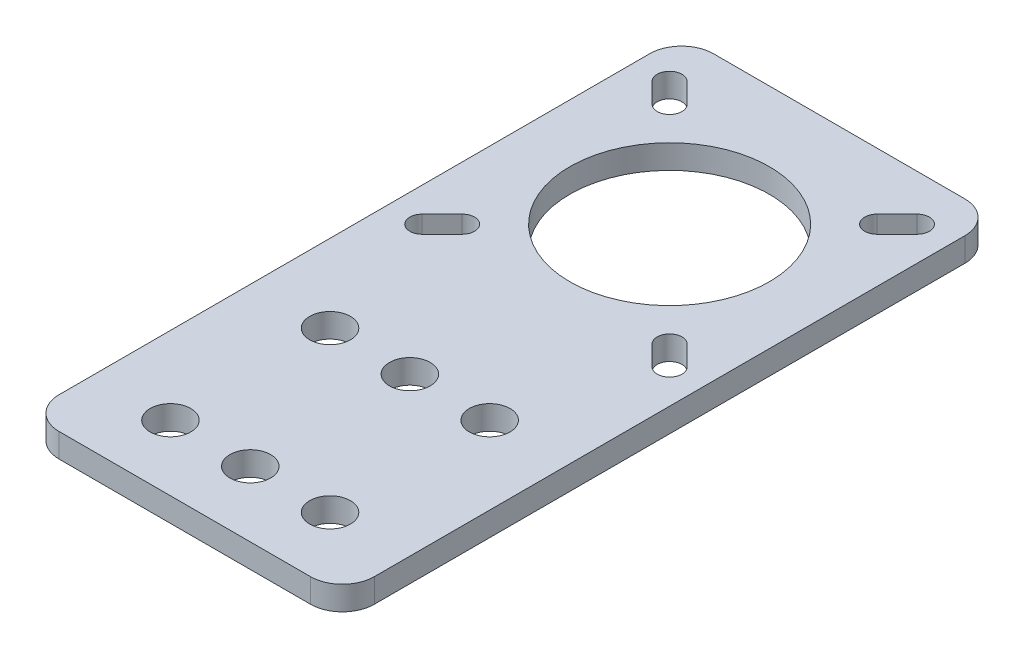
from build123d import *

# Parameters (mm, degrees)
SKETCH1_R           = 12.5
SKETCH1_R_2         = 2.55
BOSS_EXTRUDE1_DEPTH = 3


with BuildPart() as part:
    # Sketch1 → Boss-Extrude1 (new body)
    with BuildSketch(Plane(origin=(0, 0, 0), x_dir=(1, 0, 0), z_dir=(0, 1, 0))):
        with BuildLine():
            Line((15.75, -60.75), (-15.75, -60.75))
            ThreePointArc((-15.75, -60.75), (-18.578427125, -59.578427125), (-19.75, -56.75))
            Line((-19.75, -56.75), (-19.75, 17.25))
            ThreePointArc((-19.75, 17.25), (-18.578427125, 20.078427125), (-15.75, 21.25))
            Line((-15.75, 21.25), (15.75, 21.25))
            ThreePointArc((15.75, 21.25), (18.578427125, 20.078427125), (19.75, 17.25))
            Line((19.75, 17.25), (19.75, -56.75))
            ThreePointArc((19.75, -56.75), (18.578427125, -59.578427125), (15.75, -60.75))
        make_face()
        Circle(SKETCH1_R, mode=Mode.SUBTRACT)
        with Locations((10, -52.55)):
            Circle(SKETCH1_R_2, mode=Mode.SUBTRACT)
        with Locations((10, -32.55)):
            Circle(SKETCH1_R_2, mode=Mode.SUBTRACT)
        with Locations((0, -52.55)):
            Circle(SKETCH1_R_2, mode=Mode.SUBTRACT)
        with Locations((0, -32.55)):
            Circle(SKETCH1_R_2, mode=Mode.SUBTRACT)
        with Locations((-10, -52.55)):
            Circle(SKETCH1_R_2, mode=Mode.SUBTRACT)
        with Locations((-10, -32.55)):
            Circle(SKETCH1_R_2, mode=Mode.SUBTRACT)
        with BuildLine():
            Line((11.903984489, 14.096015511), (14.403984489, 16.596015511))
            ThreePointArc((14.403984489, 16.596015511), (16.596015511, 16.596015511), (16.596015511, 14.403984489))
            Line((16.596015511, 14.403984489), (14.096015511, 11.903984489))
            ThreePointArc((14.096015511, 11.903984489), (11.903984489, 11.903984489), (11.903984489, 14.096015511))
        make_face(mode=Mode.SUBTRACT)
        with BuildLine():
            Line((-11.903984489, 14.096015511), (-14.403984489, 16.596015511))
            ThreePointArc((-14.403984489, 16.596015511), (-16.596015511, 16.596015511), (-16.596015511, 14.403984489))
            Line((-16.596015511, 14.403984489), (-14.096015511, 11.903984489))
            ThreePointArc((-14.096015511, 11.903984489), (-11.903984489, 11.903984489), (-11.903984489, 14.096015511))
        make_face(mode=Mode.SUBTRACT)
        with BuildLine():
            Line((-11.903984489, -14.096015511), (-14.403984489, -16.596015511))
            ThreePointArc((-14.403984489, -16.596015511), (-16.596015511, -16.596015511), (-16.596015511, -14.403984489))
            Line((-16.596015511, -14.403984489), (-14.096015511, -11.903984489))
            ThreePointArc((-14.096015511, -11.903984489), (-11.903984489, -11.903984489), (-11.903984489, -14.096015511))
        make_face(mode=Mode.SUBTRACT)
        with BuildLine():
            Line((11.903984489, -14.096015511), (14.403984489, -16.596015511))
            ThreePointArc((14.403984489, -16.596015511), (16.596015511, -16.596015511), (16.596015511, -14.403984489))
            Line((16.596015511, -14.403984489), (14.096015511, -11.903984489))
            ThreePointArc((14.096015511, -11.903984489), (11.903984489, -11.903984489), (11.903984489, -14.096015511))
        make_face(mode=Mode.SUBTRACT)
    extrude(amount=BOSS_EXTRUDE1_DEPTH)


solid = part.part
